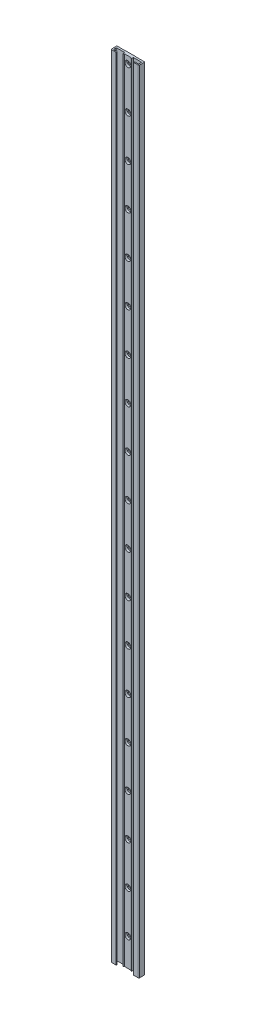
from build123d import *

# Parameters (mm, degrees)
SKETCH1_W                                        = 40
SKETCH1_H                                        = 1130.3
BOSS_EXTRUDE1_DEPTH                              = 8.7
CUT_EXTRUDE1_DEPTH                               = 1131.3
SKETCH3_W                                        = 12
SKETCH3_H                                        = 0.2
CUT_EXTRUDE2_DEPTH                               = 1131.3
SKETCH4_W                                        = 12
SKETCH4_H                                        = 0.2
CUT_EXTRUDE3_DEPTH                               = 1131.3
DRAFT1_ANGLE                                     = 45
CBORE_FOR_M4_HEX_HEAD_MACHINE_SCREW1_D           = 4.5
CBORE_FOR_M4_HEX_HEAD_MACHINE_SCREW1_DEPTH       = 4.5
CBORE_FOR_M4_HEX_HEAD_MACHINE_SCREW1_CBORE_D     = 8.5
CBORE_FOR_M4_HEX_HEAD_MACHINE_SCREW1_CBORE_DEPTH = 3.1
FILLET1_R                                        = 0.5
FILLET2_R                                        = 1


with BuildPart() as part:
    # Sketch1 → Boss-Extrude1 (new body)
    with BuildSketch(Plane.XY.offset(8.7)):
        with Locations((0, 565.15)):
            Rectangle(SKETCH1_W, SKETCH1_H)
    extrude(amount=-BOSS_EXTRUDE1_DEPTH)

    # Sketch2 → Cut-Extrude1 (cut, through all)
    with BuildSketch(Plane.XZ):
        Polygon((12.5, 8.7), (-12.5, 8.7), (-12.5, 7.2), (-18, 7.2), (-18, 2.8), (-6.3, 2.8), (-6.3, 5.5), (-4.75, 5.5), (-4.75, 4.5), (4.75, 4.5), (4.75, 5.5), (6.3, 5.5), (6.3, 2.8), (18, 2.8), (18, 7.2), (12.5, 7.2), align=None)
    extrude(amount=-CUT_EXTRUDE1_DEPTH, mode=Mode.SUBTRACT)

    # Sketch3 → Cut-Extrude2 (cut, through all)
    with BuildSketch(Plane.XZ):
        with Locations((14, 0.1)):
            Rectangle(SKETCH3_W, SKETCH3_H)
    extrude(amount=-CUT_EXTRUDE2_DEPTH, mode=Mode.SUBTRACT)

    # Sketch4 → Cut-Extrude3 (cut, through all)
    with BuildSketch(Plane.XZ):
        with Locations((-14, 0.1)):
            Rectangle(SKETCH4_W, SKETCH4_H)
    extrude(amount=-CUT_EXTRUDE3_DEPTH, mode=Mode.SUBTRACT)

    # Draft1
    draft1_faces = [part.faces().sort_by_distance(p)[0] for p in [
        (4.75, 565.15, 5),
        (-4.75, 565.15, 5),
    ]]
    draft(draft1_faces, Plane(origin=(-4.75, 1130.3, 4.5), x_dir=(1, 0, 0), z_dir=(0, 0, 1)), DRAFT1_ANGLE)

    # CBORE for M4 Hex Head Machine Screw1
    with Locations(Plane.XY.offset(4.5)):
        with Locations((0, 160), (0, 100), (0, 40), (0, 220), (0, 280), (0, 340), (0, 400), (0, 460), (0, 520), (0, 580), (0, 640), (0, 700), (0, 760), (0, 820), (0, 880), (0, 940), (0, 1000), (0, 1060), (0, 1120), (0, 1180)):
            CounterBoreHole(CBORE_FOR_M4_HEX_HEAD_MACHINE_SCREW1_D / 2, CBORE_FOR_M4_HEX_HEAD_MACHINE_SCREW1_CBORE_D / 2, CBORE_FOR_M4_HEX_HEAD_MACHINE_SCREW1_CBORE_DEPTH, depth=CBORE_FOR_M4_HEX_HEAD_MACHINE_SCREW1_DEPTH)

    # Fillet1
    fillet1_edges = [part.edges().sort_by_distance(p)[0] for p in [
        (18, 565.15, 7.2),
        (18, 565.15, 2.8),
        (-18, 565.15, 2.8),
        (-18, 565.15, 7.2),
        (20, 565.15, 0.2),
        (-20, 565.15, 0.2),
    ]]
    fillet(fillet1_edges, radius=FILLET1_R)

    # Fillet2
    fillet2_edges = [part.edges().sort_by_distance(p)[0] for p in [
        (20, 565.15, 8.7),
        (-20, 565.15, 8.7),
    ]]
    fillet(fillet2_edges, radius=FILLET2_R)


solid = part.part
